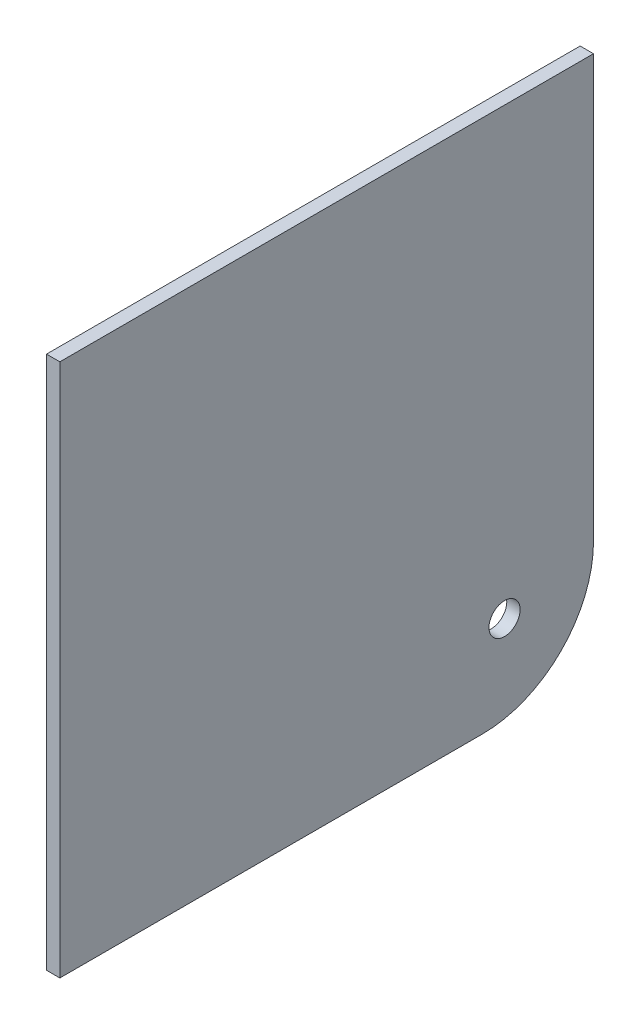
from build123d import *

# Parameters (mm, degrees)
SKETCH1_R           = 3.5
BOSS_EXTRUDE1_DEPTH = 3


with BuildPart() as part:
    # Sketch1 → Boss-Extrude1 (new body)
    with BuildSketch(Plane(origin=(0, 0, 0), x_dir=(0, 0, -1), z_dir=(1, 0, 0))):
        with BuildLine():
            Line((60, 60), (-60, 60))
            Line((-60, 60), (-60, -60))
            Line((-60, -60), (35, -60))
            ThreePointArc((35, -60), (52.67766953, -52.67766953), (60, -35))
            Line((60, -35), (60, 60))
        make_face()
        with Locations((40, -40)):
            Circle(SKETCH1_R, mode=Mode.SUBTRACT)
    extrude(amount=BOSS_EXTRUDE1_DEPTH)


solid = part.part
